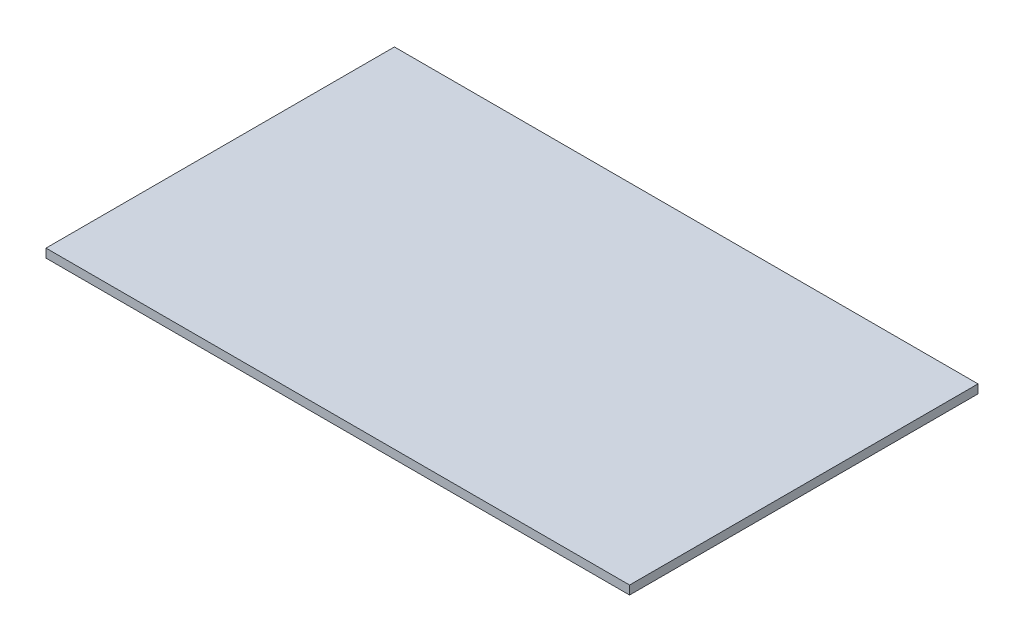
from build123d import *

# Parameters (mm, degrees)
SKETCH1_W      = 670
SKETCH1_H      = 400
EXTRUDE1_DEPTH = 10


with BuildPart() as part:
    # Sketch1 → Extrude1 (new body)
    with BuildSketch(Plane(origin=(0, 0, 0), x_dir=(1, 0, 0), z_dir=(0, 1, 0))):
        with Locations((335, 200)):
            Rectangle(SKETCH1_W, SKETCH1_H)
    extrude(amount=EXTRUDE1_DEPTH)


solid = part.part
